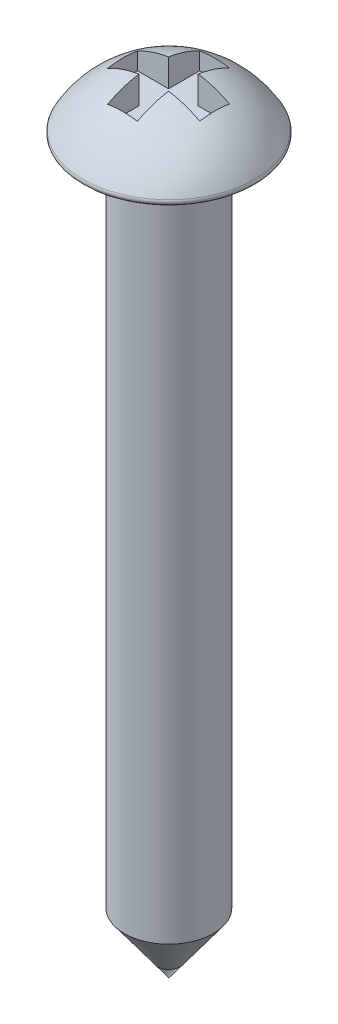
from build123d import *

# Parameters (mm, degrees)
CONG_1_R                = 0.1
ENL_V_MAT_EXTRU_1_DEPTH = 0.5


with BuildPart() as part:
    # Esquisse1 → Révolution1 (revolve)
    with BuildSketch(Plane.XY):
        with BuildLine():
            Line((2.2, 0), (1.1, 0))
            Line((1.1, 0), (1.1, -16.5))
            Line((1.1, -16.5), (0, -18))
            Line((0, -18), (0, 1.392961166))
            ThreePointArc((0, 1.392961166), (1.301954378, 1.015441113), (2.2, 0))
        make_face()
    revolve(axis=Axis((0, 3.800054794, 0), (0, -1, 0)))

    # Congé1
    cong_1_edges = [part.edges().sort_by_distance(p)[0] for p in [
        (-2.2, 0, 0),
    ]]
    fillet(cong_1_edges, radius=CONG_1_R)

    # Esquisse2 → Enlèv. mat.-Extru.1 (cut, symmetric)
    with BuildSketch(Plane(origin=(0, 1.15653742, 0), x_dir=(-1, 0, 0), z_dir=(0, 1, 0))):
        Polygon((-0.361948003, 1.140760916), (0.37159995, 1.140760916), (0.37159995, 0.37038863), (1.141972235, 0.37038863), (1.141972235, -0.363159322), (0.37159995, -0.363159322), (0.37159995, -1.133531608), (-0.361948003, -1.133531608), (-0.361948003, -0.363159322), (-1.132320288, -0.363159322), (-1.132320288, 0.37038863), (-0.361948003, 0.37038863), align=None)
    extrude(amount=ENL_V_MAT_EXTRU_1_DEPTH, both=True, mode=Mode.SUBTRACT)


solid = part.part
